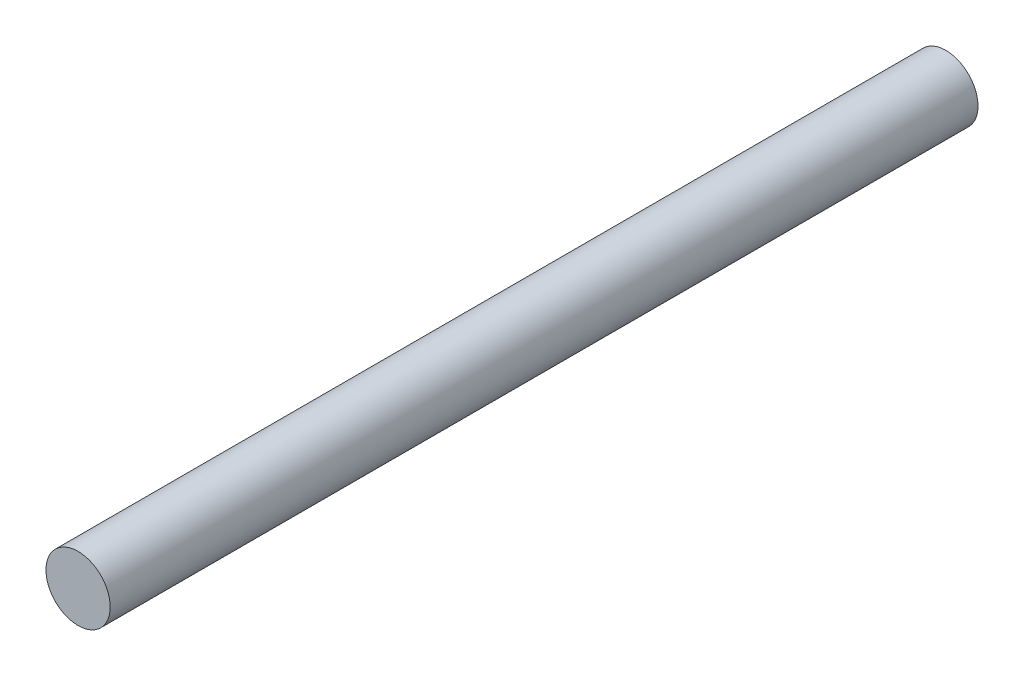
from build123d import *

# Parameters (mm, degrees)
SKETCH_1_R      = 3
EXTRUDE_1_DEPTH = 81


with BuildPart() as part:
    # 草图1 → 凸台-拉伸1 (new body)
    with BuildSketch(Plane.XY):
        Circle(SKETCH_1_R)
    extrude(amount=EXTRUDE_1_DEPTH)


solid = part.part
